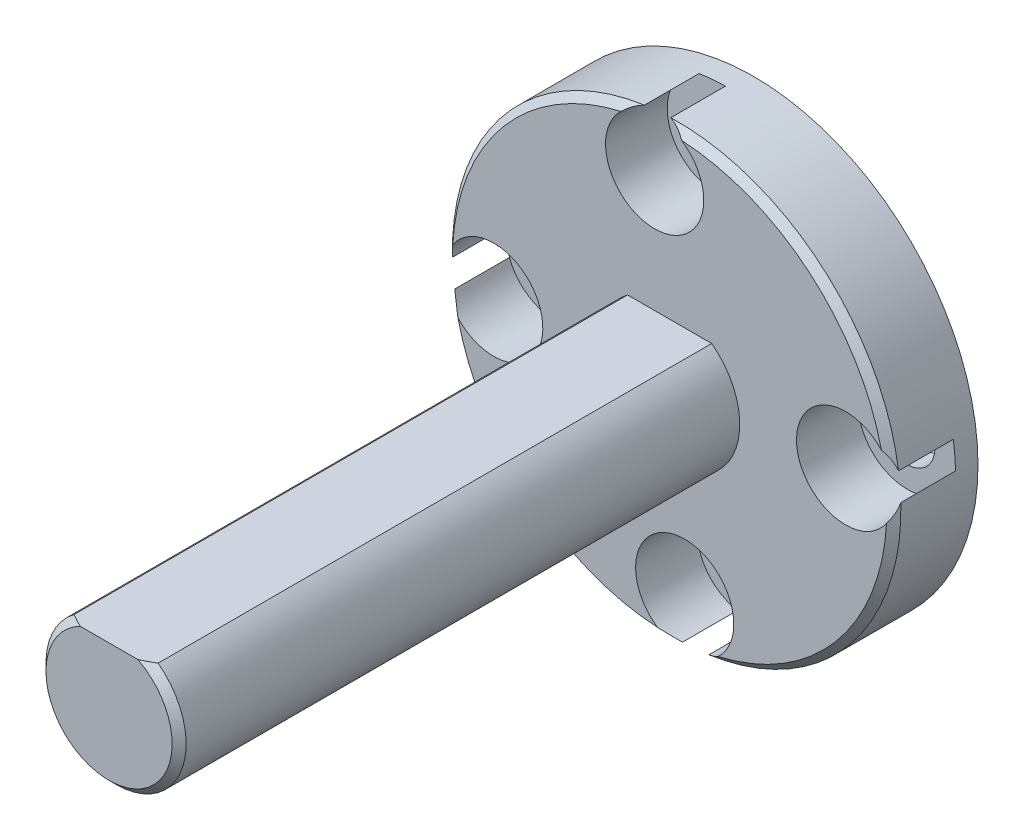
from build123d import *

# Parameters (mm, degrees)
ESQUISSE1_R             = 10.16
ESQUISSE1_R_2           = 1.25
BOSS_EXTRU_2_DEPTH      = 3.81
BOSS_EXTRU_3_DEPTH      = 25.4
CHANFREIN1_SIZE         = 0.3175
ESQUISSE3_R             = 4.445
ENL_V_MAT_EXTRU_1_DEPTH = 2.54
ESQUISSE4_R             = 2.224538278
ENL_V_MAT_EXTRU_6_DEPTH = 2.794


with BuildPart() as part:
    # Esquisse1 → Boss.-Extru.2 (new body)
    with BuildSketch(Plane.XY):
        with Locations((0.618453307, -10.014969778)):
            Circle(ESQUISSE1_R)
        with Locations((8.589458927, -9.334477749)):
            Circle(ESQUISSE1_R_2, mode=Mode.SUBTRACT)
        with Locations((1.298945336, -17.985975399)):
            Circle(ESQUISSE1_R_2, mode=Mode.SUBTRACT)
        with Locations((-7.352552313, -10.695461808)):
            Circle(ESQUISSE1_R_2, mode=Mode.SUBTRACT)
        with Locations((-0.062038722, -2.043964158)):
            Circle(ESQUISSE1_R_2, mode=Mode.SUBTRACT)
    extrude(amount=BOSS_EXTRU_2_DEPTH)

    # Esquisse2 → Boss.-Extru.3 (add)
    with BuildSketch(Plane.XY.offset(3.81)):
        with BuildLine():
            Line((-1.286546693, -7.474969778), (2.523453307, -7.474969778))
            ThreePointArc((2.523453307, -7.474969778), (0.618453307, -13.189969778), (-1.286546693, -7.474969778))
        make_face()
    extrude(amount=BOSS_EXTRU_3_DEPTH)

    # Chanfrein1
    chanfrein1_edges = [part.edges().sort_by_distance(p)[0] for p in [
        (0.618453307, -13.189969778, 29.21),
        (-9.541546693, -10.014969778, 3.81),
    ]]
    chamfer(chanfrein1_edges, length=CHANFREIN1_SIZE)

    # Esquisse3 → Enlèv. mat.-Extru.1 (cut)
    with BuildSketch(Plane(origin=(0, 0, 0), x_dir=(-1, 0, 0), z_dir=(0, 0, -1))):
        with Locations((-0.618453307, -10.014969778)):
            Circle(ESQUISSE3_R)
    extrude(amount=-ENL_V_MAT_EXTRU_1_DEPTH, mode=Mode.SUBTRACT)

    # Esquisse4 → Enlèv. mat.-Extru.6 (cut)
    with BuildSketch(Plane.XY.offset(3.81)):
        with Locations((-0.062038722, -2.043964158)):
            Circle(ESQUISSE4_R)
        with Locations((8.589458927, -9.334477749)):
            Circle(ESQUISSE4_R)
        with Locations((1.298945336, -17.985975399)):
            Circle(ESQUISSE4_R)
        with Locations((-7.352552313, -10.695461808)):
            Circle(ESQUISSE4_R)
    extrude(amount=-ENL_V_MAT_EXTRU_6_DEPTH, mode=Mode.SUBTRACT)


solid = part.part
